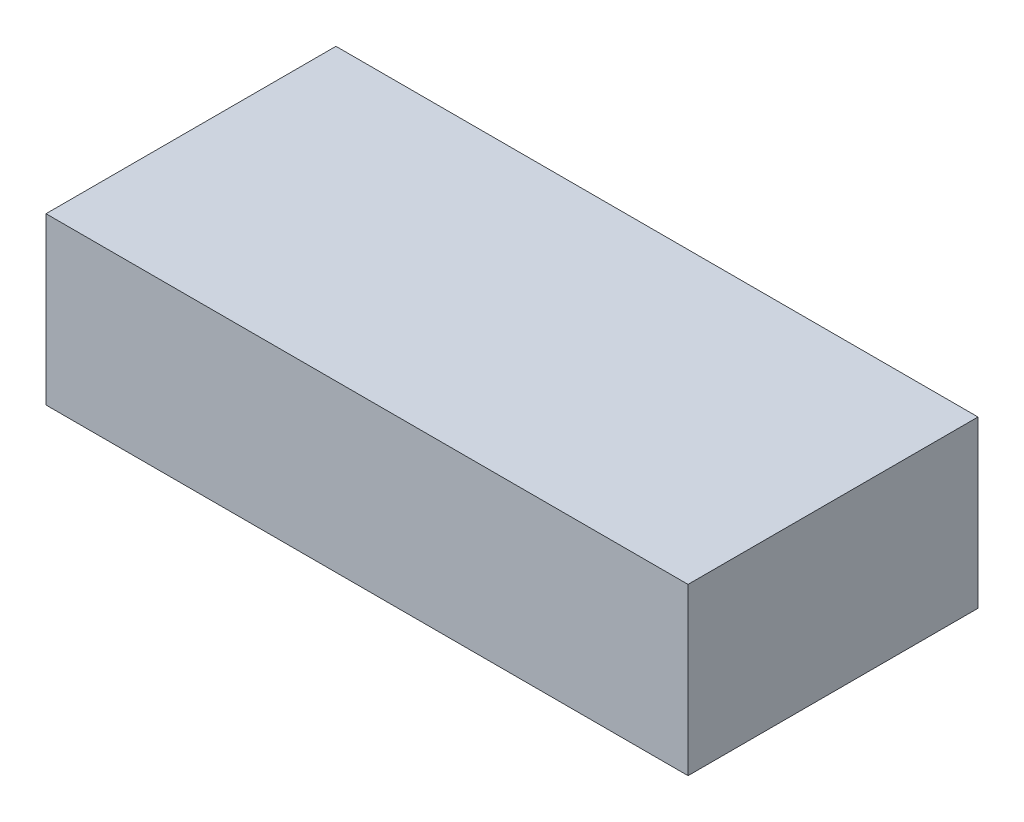
from build123d import *

# Parameters (mm, degrees)
SKETCH1_W           = 196.85
SKETCH1_H           = 88.9
BOSS_EXTRUDE1_DEPTH = 25.4


with BuildPart() as part:
    # Sketch1 → Boss-Extrude1 (new body, symmetric)
    with BuildSketch(Plane(origin=(0, 0, 0), x_dir=(1, 0, 0), z_dir=(0, 1, 0))):
        Rectangle(SKETCH1_W, SKETCH1_H)
    extrude(amount=BOSS_EXTRUDE1_DEPTH, both=True)


solid = part.part
